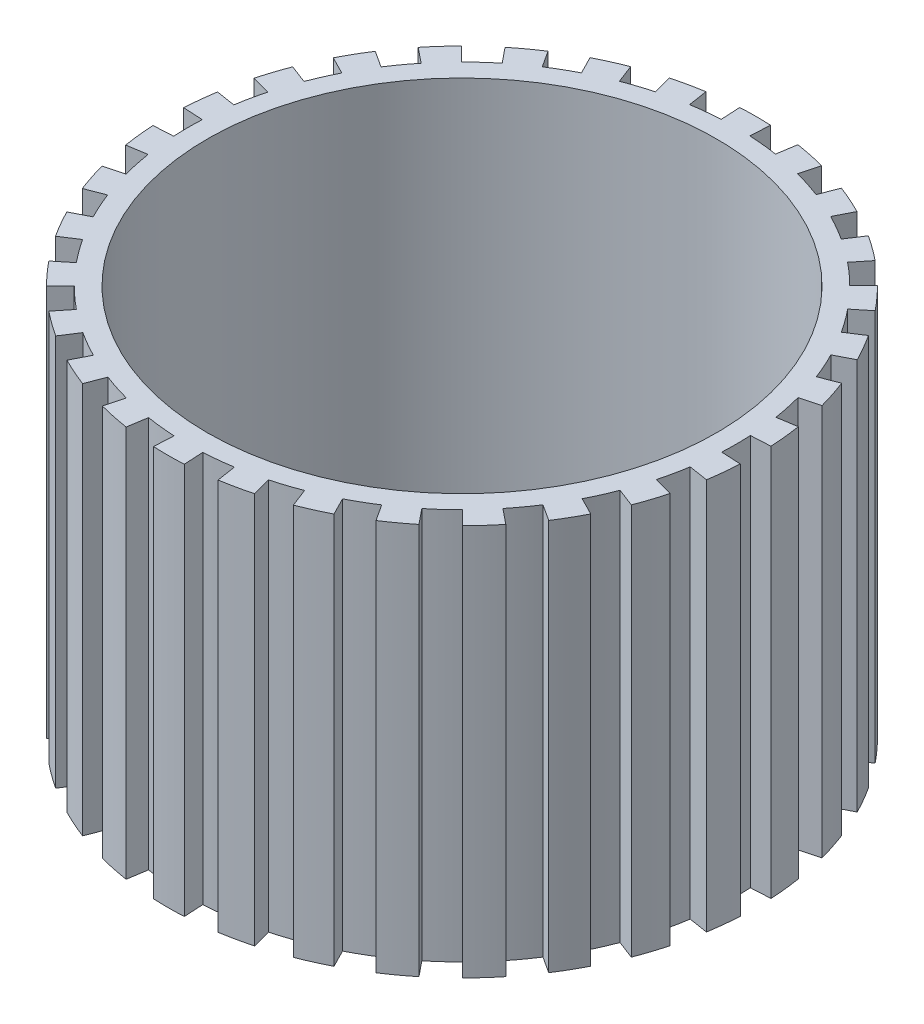
from build123d import *

# Parameters (mm, degrees)
SKETCH2_R           = 65
BOSS_EXTRUDE1_DEPTH = 100


with BuildPart() as part:
    # Sketch2 → Boss-Extrude1 (new body)
    with BuildSketch(Plane(origin=(0, 0, 0), x_dir=(1, 0, 0), z_dir=(0, 1, 0))):
        with BuildLine():
            Line((-11.012600748, 69.128305525), (-11.799215087, 74.066041634))
            ThreePointArc((-11.799215087, 74.066041634), (-15.659361787, 73.347013494), (-19.476587264, 72.426946288))
            Line((-19.476587264, 72.426946288), (-18.178148113, 67.598483202))
            ThreePointArc((-18.178148113, 67.598483202), (-21.691066852, 66.554471066), (-25.144531884, 65.32803775))
            Line((-25.144531884, 65.32803775), (-26.940569876, 69.994326161))
            ThreePointArc((-26.940569876, 69.994326161), (-30.566868752, 68.488440884), (-34.109385966, 66.79483355))
            Line((-34.109385966, 66.79483355), (-31.835426902, 62.341844647))
            ThreePointArc((-31.835426902, 62.341844647), (-35.054517609, 60.590269806), (-38.177526321, 58.672621247))
            Line((-38.177526321, 58.672621247), (-40.904492486, 62.863522765))
            ThreePointArc((-40.904492486, 62.863522765), (-44.138456878, 60.636594763), (-47.251440827, 58.243466069))
            Line((-47.251440827, 58.243466069), (-44.101344772, 54.360568332))
            ThreePointArc((-44.101344772, 54.360568332), (-46.885917737, 51.977983012), (-49.541979661, 49.452929653))
            Line((-49.541979661, 49.452929653), (-53.080692494, 52.985281771))
            ThreePointArc((-53.080692494, 52.985281771), (-55.780982638, 50.134638485), (-58.328380986, 47.146579638))
            Line((-58.328380986, 47.146579638), (-54.439822253, 44.003474329))
            ThreePointArc((-54.439822253, 44.003474329), (-56.668178276, 41.094008942), (-58.741210761, 38.071907732))
            Line((-58.741210761, 38.071907732), (-62.937011529, 40.791329713))
            ThreePointArc((-62.937011529, 40.791329713), (-64.985611789, 37.441557932), (-66.856091005, 33.989161443))
            Line((-66.856091005, 33.989161443), (-62.399018271, 31.723217347))
            ThreePointArc((-62.399018271, 31.723217347), (-63.9737675, 28.41402949), (-65.373169079, 25.026960753))
            Line((-65.373169079, 25.026960753), (-70.042681156, 26.814600807))
            ThreePointArc((-70.042681156, 26.814600807), (-71.350057871, 23.112101633), (-72.461869036, 19.346253794))
            Line((-72.461869036, 19.346253794), (-67.631077767, 18.056503541))
            ThreePointArc((-67.631077767, 18.056503541), (-68.483396104, 14.492220604), (-69.148006213, 10.888215497))
            Line((-69.148006213, 10.888215497), (-74.087149514, 11.665945176))
            ThreePointArc((-74.087149514, 11.665945176), (-74.596164047, 7.772535588), (-74.900715679, 3.857822021))
            Line((-74.900715679, 3.857822021), (-69.907334634, 3.600633886))
            ThreePointArc((-69.907334634, 3.600633886), (-69.999971679, -0.062967864), (-69.900743667, -3.726397024))
            Line((-69.900743667, -3.726397024), (-74.893653929, -3.99256824))
            ThreePointArc((-74.893653929, -3.99256824), (-74.582059903, -7.906727558), (-74.066041634, -11.799215087))
            Line((-74.066041634, -11.799215087), (-69.128305525, -11.012600748))
            ThreePointArc((-69.128305525, -11.012600748), (-68.457212594, -14.615404334), (-67.598483202, -18.178148113))
            Line((-67.598483202, -18.178148113), (-72.426946288, -19.476587264))
            ThreePointArc((-72.426946288, -19.476587264), (-71.308361856, -23.24042877), (-69.994326161, -26.940569876))
            Line((-69.994326161, -26.940569876), (-65.32803775, -25.144531884))
            ThreePointArc((-65.32803775, -25.144531884), (-63.922544825, -28.529077502), (-62.341844647, -31.835426902))
            Line((-62.341844647, -31.835426902), (-66.79483355, -34.109385966))
            ThreePointArc((-66.79483355, -34.109385966), (-64.918146221, -37.558411724), (-62.863522765, -40.904492486))
            Line((-62.863522765, -40.904492486), (-58.672621247, -38.177526321))
            ThreePointArc((-58.672621247, -38.177526321), (-56.594155112, -41.195893086), (-54.360568332, -44.101344772))
            Line((-54.360568332, -44.101344772), (-58.243466069, -47.251440827))
            ThreePointArc((-58.243466069, -47.251440827), (-55.690696084, -50.234911861), (-52.985281771, -53.080692494))
            Line((-52.985281771, -53.080692494), (-49.452929653, -49.541979661))
            ThreePointArc((-49.452929653, -49.541979661), (-46.792329252, -52.062250462), (-44.003474329, -54.439822253))
            Line((-44.003474329, -54.439822253), (-47.146579638, -58.328380986))
            ThreePointArc((-47.146579638, -58.328380986), (-44.029295295, -60.715905296), (-40.791329713, -62.937011529))
            Line((-40.791329713, -62.937011529), (-38.071907732, -58.741210761))
            ThreePointArc((-38.071907732, -58.741210761), (-34.94545407, -60.65323767), (-31.723217347, -62.399018271))
            Line((-31.723217347, -62.399018271), (-33.989161443, -66.856091005))
            ThreePointArc((-33.989161443, -66.856091005), (-30.443603025, -68.543322321), (-26.814600807, -70.042681156))
            Line((-26.814600807, -70.042681156), (-25.026960753, -65.373169079))
            ThreePointArc((-25.026960753, -65.373169079), (-21.571294857, -66.593387346), (-18.056503541, -67.631077767))
            Line((-18.056503541, -67.631077767), (-19.346253794, -72.461869036))
            ThreePointArc((-19.346253794, -72.461869036), (-15.527379218, -73.375067255), (-11.665945176, -74.087149514))
            Line((-11.665945176, -74.087149514), (-10.888215497, -69.148006213))
            ThreePointArc((-10.888215497, -69.148006213), (-7.254366549, -69.623086444), (-3.600633886, -69.907334634))
            Line((-3.600633886, -69.907334634), (-3.857822021, -74.900715679))
            ThreePointArc((-3.857822021, -74.900715679), (0.067465569, -74.999969656), (3.99256824, -74.893653929))
            Line((3.99256824, -74.893653929), (3.726397024, -69.900743667))
            ThreePointArc((3.726397024, -69.900743667), (7.379612388, -69.609922576), (11.012600748, -69.128305525))
            Line((11.012600748, -69.128305525), (11.799215087, -74.066041634))
            ThreePointArc((11.799215087, -74.066041634), (15.659361787, -73.347013494), (19.476587264, -72.426946288))
            Line((19.476587264, -72.426946288), (18.178148113, -67.598483202))
            ThreePointArc((18.178148113, -67.598483202), (21.691066852, -66.554471066), (25.144531884, -65.32803775))
            Line((25.144531884, -65.32803775), (26.940569876, -69.994326161))
            ThreePointArc((26.940569876, -69.994326161), (30.566868752, -68.488440884), (34.109385966, -66.79483355))
            Line((34.109385966, -66.79483355), (31.835426902, -62.341844647))
            ThreePointArc((31.835426902, -62.341844647), (35.054517609, -60.590269806), (38.177526321, -58.672621247))
            Line((38.177526321, -58.672621247), (40.904492486, -62.863522765))
            ThreePointArc((40.904492486, -62.863522765), (44.138456878, -60.636594763), (47.251440827, -58.243466069))
            Line((47.251440827, -58.243466069), (44.101344772, -54.360568332))
            ThreePointArc((44.101344772, -54.360568332), (46.885917737, -51.977983012), (49.541979661, -49.452929653))
            Line((49.541979661, -49.452929653), (53.080692494, -52.985281771))
            ThreePointArc((53.080692494, -52.985281771), (55.780982638, -50.134638485), (58.328380986, -47.146579638))
            Line((58.328380986, -47.146579638), (54.439822253, -44.003474329))
            ThreePointArc((54.439822253, -44.003474329), (56.668178276, -41.094008942), (58.741210761, -38.071907732))
            Line((58.741210761, -38.071907732), (62.937011529, -40.791329713))
            ThreePointArc((62.937011529, -40.791329713), (64.985611789, -37.441557932), (66.856091005, -33.989161443))
            Line((66.856091005, -33.989161443), (62.399018271, -31.723217347))
            ThreePointArc((62.399018271, -31.723217347), (63.9737675, -28.41402949), (65.373169079, -25.026960753))
            Line((65.373169079, -25.026960753), (70.042681156, -26.814600807))
            ThreePointArc((70.042681156, -26.814600807), (71.350057871, -23.112101633), (72.461869036, -19.346253794))
            Line((72.461869036, -19.346253794), (67.631077767, -18.056503541))
            ThreePointArc((67.631077767, -18.056503541), (68.483396104, -14.492220604), (69.148006213, -10.888215497))
            Line((69.148006213, -10.888215497), (74.087149514, -11.665945176))
            ThreePointArc((74.087149514, -11.665945176), (74.596164047, -7.772535588), (74.900715679, -3.857822021))
            Line((74.900715679, -3.857822021), (69.907334634, -3.600633886))
            ThreePointArc((69.907334634, -3.600633886), (69.999971679, 0.062967864), (69.900743667, 3.726397024))
            Line((69.900743667, 3.726397024), (74.893653929, 3.99256824))
            ThreePointArc((74.893653929, 3.99256824), (74.582059903, 7.906727558), (74.066041634, 11.799215087))
            Line((74.066041634, 11.799215087), (69.128305525, 11.012600748))
            ThreePointArc((69.128305525, 11.012600748), (68.457212594, 14.615404334), (67.598483202, 18.178148113))
            Line((67.598483202, 18.178148113), (72.426946288, 19.476587264))
            ThreePointArc((72.426946288, 19.476587264), (71.308361856, 23.24042877), (69.994326161, 26.940569876))
            Line((69.994326161, 26.940569876), (65.32803775, 25.144531884))
            ThreePointArc((65.32803775, 25.144531884), (63.922544825, 28.529077502), (62.341844647, 31.835426902))
            Line((62.341844647, 31.835426902), (66.79483355, 34.109385966))
            ThreePointArc((66.79483355, 34.109385966), (64.918146221, 37.558411724), (62.863522765, 40.904492486))
            Line((62.863522765, 40.904492486), (58.672621247, 38.177526321))
            ThreePointArc((58.672621247, 38.177526321), (56.594155112, 41.195893086), (54.360568332, 44.101344772))
            Line((54.360568332, 44.101344772), (58.243466069, 47.251440827))
            ThreePointArc((58.243466069, 47.251440827), (55.690696084, 50.234911861), (52.985281771, 53.080692494))
            Line((52.985281771, 53.080692494), (49.452929653, 49.541979661))
            ThreePointArc((49.452929653, 49.541979661), (46.792329252, 52.062250462), (44.003474329, 54.439822253))
            Line((44.003474329, 54.439822253), (47.146579638, 58.328380986))
            ThreePointArc((47.146579638, 58.328380986), (44.029295295, 60.715905296), (40.791329713, 62.937011529))
            Line((40.791329713, 62.937011529), (38.071907732, 58.741210761))
            ThreePointArc((38.071907732, 58.741210761), (34.94545407, 60.65323767), (31.723217347, 62.399018271))
            Line((31.723217347, 62.399018271), (33.989161443, 66.856091005))
            ThreePointArc((33.989161443, 66.856091005), (30.443603025, 68.543322321), (26.814600807, 70.042681156))
            Line((26.814600807, 70.042681156), (25.026960753, 65.373169079))
            ThreePointArc((25.026960753, 65.373169079), (21.571294857, 66.593387346), (18.056503541, 67.631077767))
            Line((18.056503541, 67.631077767), (19.346253794, 72.461869036))
            ThreePointArc((19.346253794, 72.461869036), (15.527379218, 73.375067255), (11.665945176, 74.087149514))
            Line((11.665945176, 74.087149514), (10.888215497, 69.148006213))
            ThreePointArc((10.888215497, 69.148006213), (7.254366549, 69.623086444), (3.600633886, 69.907334634))
            Line((3.600633886, 69.907334634), (3.857822021, 74.900715679))
            ThreePointArc((3.857822021, 74.900715679), (-0.067465569, 74.999969656), (-3.99256824, 74.893653929))
            Line((-3.99256824, 74.893653929), (-3.726397024, 69.900743667))
            ThreePointArc((-3.726397024, 69.900743667), (-7.379612388, 69.609922576), (-11.012600748, 69.128305525))
        make_face()
        Circle(SKETCH2_R, mode=Mode.SUBTRACT)
    extrude(amount=BOSS_EXTRUDE1_DEPTH)


solid = part.part
